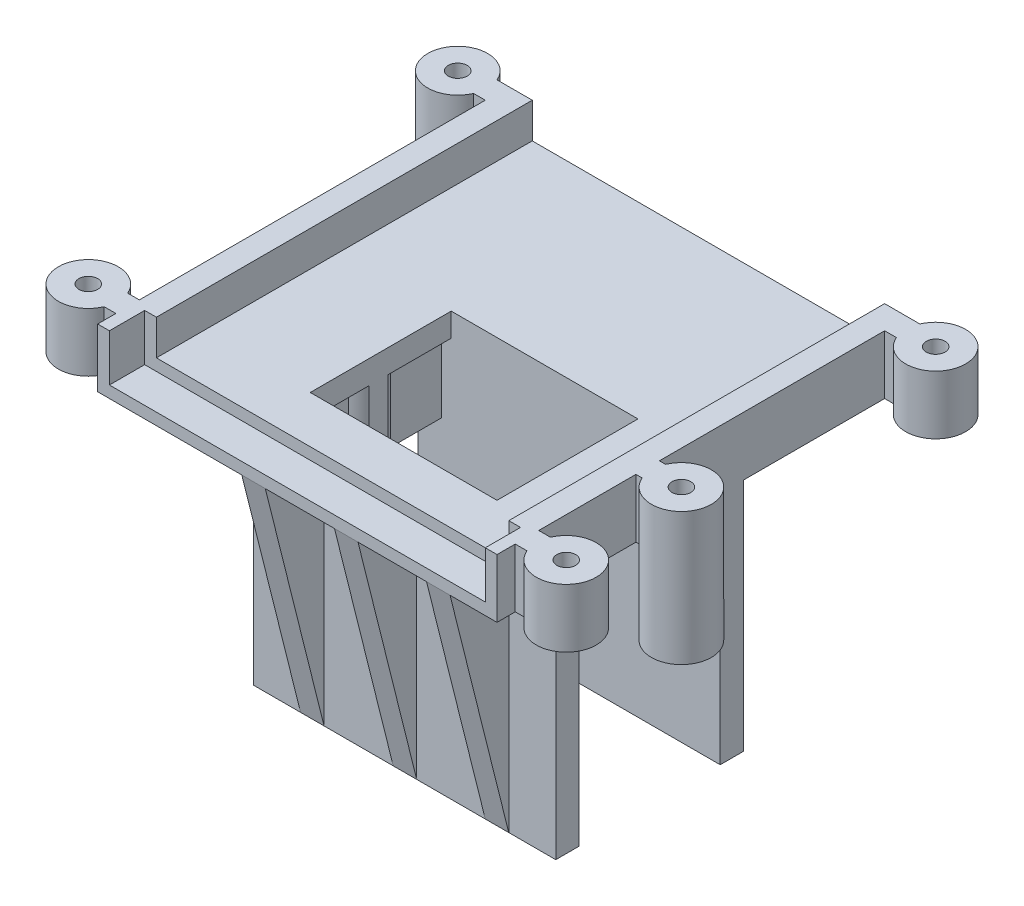
from build123d import *

# Parameters (mm, degrees)
BOSS_EXTRU_1_DEPTH       = 35
ENL_V_MAT_EXTRU_1_DEPTH  = 3
ENL_V_START              = -2
ESQUISSE3_W              = 14
ESQUISSE3_H              = 12
ENL_V_MAT_EXTRU_2_DEPTH  = 2
ESQUISSE7_W              = 3
ESQUISSE7_H              = 12
ENL_V_MAT_EXTRU_4_DEPTH  = 2
BOSS_EXTRU_4_START       = -2
ESQUISSE9_W              = 1.1
ESQUISSE9_H              = 12
BOSS_EXTRU_4_DEPTH       = 2
ESQUISSE10_R             = 0.8
BOSS_EXTRU_5_DEPTH       = 6.285817
ESQUISSE19_W             = 2
ESQUISSE19_H             = 4.092832792
ESQUISSE19_H_2           = 4.443065592
ESQUISSE19_W_2           = 4
ESQUISSE19_H_3           = 2
BOSS_EXTRU_8_DEPTH       = 6.285817
ENL_V_MAT_EXTRU_9_DEPTH  = 2
ESQUISSE25_R             = 0.8
BOSS_EXTRU_10_DEPTH      = 5
ESQUISSE26_R             = 0.8
BOSS_EXTRU_11_DEPTH      = 5
ESQUISSE27_R             = 0.8
BOSS_EXTRU_12_DEPTH      = 5
ESQUISSE28_R             = 2.55
ESQUISSE28_R_2           = 0.8
BOSS_EXTRU_13_DEPTH      = 6.290743
ENL_V_START_2            = -6.290743
ESQUISSE29_W             = 1.350487441
ESQUISSE29_H             = 4.654500935
ENL_V_MAT_EXTRU_11_DEPTH = 6.290743
BOSS_EXTRU_14_DEPTH      = 20
ENL_V_START_3            = -17.727203
ENL_V_MAT_EXTRU_12_DEPTH = 17.727203


with BuildPart() as part:
    # Esquisse1 → Boss.-Extru.1 (new body)
    with BuildSketch(Plane.XY):
        Polygon((0, 0), (34, 0), (34, 5), (32, 5), (32, 2), (2, 2), (2, 5), (0, 5), align=None)
    extrude(amount=BOSS_EXTRU_1_DEPTH)

    # Esquisse2 → Enl_v. mat.-Extru.1 (cut)
    with BuildSketch(Plane.XY.offset(35)):
        Polygon((2, 5), (1, 5), (1, 1), (33, 1), (33, 5), (32, 5), (32, 2), (2, 2), align=None)
    extrude(amount=-ENL_V_MAT_EXTRU_1_DEPTH, mode=Mode.SUBTRACT)

    # Esquisse3 → Enl_v. mat.-Extru.2 (cut)
    with BuildSketch(Plane(origin=(0, 2, 0), x_dir=(1, 0, 0), z_dir=(0, 1, 0)).offset(ENL_V_START)):
        with Locations((17, -22)):
            Rectangle(ESQUISSE3_W, ESQUISSE3_H)
    extrude(amount=ENL_V_MAT_EXTRU_2_DEPTH, mode=Mode.SUBTRACT)

    # Esquisse7 → Enl_v. mat.-Extru.4 (cut)
    with BuildSketch(Plane.XZ.offset(ENL_V_START)):
        with Locations((25.5, 22)):
            Rectangle(ESQUISSE7_W, ESQUISSE7_H)
    extrude(amount=ENL_V_MAT_EXTRU_4_DEPTH, mode=Mode.SUBTRACT)

    # Esquisse9 → Boss.-Extru.4 (add)
    with BuildSketch(Plane.XZ.offset(BOSS_EXTRU_4_START)):
        with Locations((10.55, 22)):
            Rectangle(ESQUISSE9_W, ESQUISSE9_H)
    extrude(amount=BOSS_EXTRU_4_DEPTH)

    # Esquisse10 → Boss.-Extru.5 (add)
    with BuildSketch(Plane.XZ):
        with BuildLine():
            Line((11.1, 22.988338073), (11.1, 21.361894727))
            ThreePointArc((11.1, 21.361894727), (7.27279708, 22.1751164), (11.1, 22.988338073))
        make_face()
        with Locations(Location((9.27279708, 22.1751164, 0), (0, 0, 90))):
            Circle(ESQUISSE10_R, mode=Mode.SUBTRACT)
    extrude(amount=BOSS_EXTRU_5_DEPTH)

    # Esquisse19 → Boss.-Extru.8 (add)
    with BuildSketch(Plane.XZ):
        with Locations((9.27279708, 25.953583604)):
            Rectangle(ESQUISSE19_W, ESQUISSE19_H)
        with Locations((9.27279708, 18.221532796)):
            Rectangle(ESQUISSE19_W, ESQUISSE19_H_2)
        with Locations((5.540746272, 22.1751164)):
            Rectangle(ESQUISSE19_W_2, ESQUISSE19_H_3)
    extrude(amount=BOSS_EXTRU_8_DEPTH)

    # Esquisse21 → Enl_v. mat.-Extru.9 (cut)
    with BuildSketch(Plane(origin=(0, 0, 21.1751164), x_dir=(-1, 0, 0), z_dir=(0, 0, -1))):
        Polygon((-3.540746272, 0), (-7.540746272, -6.285817331), (-3.540746272, -6.285817331), align=None)
    extrude(amount=-ENL_V_MAT_EXTRU_9_DEPTH, mode=Mode.SUBTRACT)

    # Esquisse25 → Boss.-Extru.10 (add)
    with BuildSketch(Plane.XZ):
        with BuildLine():
            Line((0, 31.45), (-1, 31.45))
            ThreePointArc((-1, 31.45), (-5.895740821, 32.45), (-1, 33.45))
            Line((-1, 33.45), (0, 33.45))
            Line((0, 33.45), (0, 31.45))
        make_face()
        with Locations(Location((-3.345740821, 32.45, 0), (0, 0, 270))):
            Circle(ESQUISSE25_R, mode=Mode.SUBTRACT)
        with BuildLine():
            Line((34, 33.45), (35, 33.45))
            ThreePointArc((35, 33.45), (39.895740821, 32.45), (35, 31.45))
            Line((35, 31.45), (34, 31.45))
            Line((34, 31.45), (34, 33.45))
        make_face()
        with Locations(Location((37.345740821, 32.45, 0), (0, 0, 90))):
            Circle(ESQUISSE25_R, mode=Mode.SUBTRACT)
    extrude(amount=-BOSS_EXTRU_10_DEPTH)

    # Esquisse26 → Boss.-Extru.11 (add)
    with BuildSketch(Plane.XZ):
        with BuildLine():
            Line((-1, 2), (0, 2))
            Line((0, 2), (0, 0))
            Line((0, 0), (-1, 0))
            ThreePointArc((-1, 0), (-5.895740821, 1), (-1, 2))
        make_face()
        with Locations(Location((-3.345740821, 1, 0), (0, 0, 270))):
            Circle(ESQUISSE26_R, mode=Mode.SUBTRACT)
        with BuildLine():
            Line((34, 2), (34, 0))
            Line((34, 0), (35, 0))
            ThreePointArc((35, 0), (39.895740821, 1), (35, 2))
            Line((35, 2), (34, 2))
        make_face()
        with Locations(Location((37.345740821, 1, 0), (0, 0, 90))):
            Circle(ESQUISSE26_R, mode=Mode.SUBTRACT)
    extrude(amount=-BOSS_EXTRU_11_DEPTH)

    # Esquisse27 → Boss.-Extru.12 (add)
    with BuildSketch(Plane(origin=(0, 0, 0), x_dir=(-1, 0, 0), z_dir=(0, -1, 0))):
        with BuildLine():
            Line((-34, -21.1751164), (-34.527056259, -21.1751164))
            ThreePointArc((-34.527056259, -21.1751164), (-39.42279708, -22.1751164), (-34.527056259, -23.1751164))
            Line((-34.527056259, -23.1751164), (-34, -23.1751164))
            Line((-34, -23.1751164), (-34, -21.1751164))
        make_face()
        with Locations(Location((-36.87279708, -22.1751164, 0), (0, 0, 90))):
            Circle(ESQUISSE27_R, mode=Mode.SUBTRACT)
    extrude(amount=-BOSS_EXTRU_12_DEPTH)

    # Esquisse28 → Boss.-Extru.13 (add)
    with BuildSketch(Plane.XZ):
        with Locations(Location((36.87279708, 22.1751164, 0), (0, 0, 270))):
            Circle(ESQUISSE28_R)
        with Locations(Location((36.87279708, 22.1751164, 0), (0, 0, 270))):
            Circle(ESQUISSE28_R_2, mode=Mode.SUBTRACT)
    extrude(amount=BOSS_EXTRU_13_DEPTH)

    # Esquisse29 → Enl_v. mat.-Extru.11 (cut)
    with BuildSketch(Plane.XZ.offset(6.290743087).offset(ENL_V_START_2)):
        with Locations((34.324427693, 22.303512705)):
            Rectangle(ESQUISSE29_W, ESQUISSE29_H)
    extrude(amount=ENL_V_MAT_EXTRU_11_DEPTH, mode=Mode.SUBTRACT)

    # Esquisse30 → Boss.-Extru.14 (add)
    with BuildSketch(Plane.XZ):
        Polygon((8.27279708, 28), (34, 28), (34, 30), (30, 30), (30, 35), (28, 35), (28, 30), (22.16279708, 30), (22.16279708, 35), (20.16279708, 35), (20.16279708, 30), (14.27279708, 30), (14.27279708, 35), (12.27279708, 35), (12.27279708, 30), (8.27279708, 30), align=None)
        Polygon((8.27279708, 16), (34, 16), (34, 14), (30, 14), (30, 9), (28, 9), (28, 14), (22.11, 14), (22.11, 9), (20.11, 9), (20.11, 14), (14.27279708, 14), (14.27279708, 9), (12.27279708, 9), (12.27279708, 14), (8.27279708, 14), align=None)
    extrude(amount=BOSS_EXTRU_14_DEPTH)

    # Esquisse31 → Enl_v. mat.-Extru.12 (cut)
    with BuildSketch(Plane(origin=(30, 0, 0), x_dir=(0, 0, -1), z_dir=(1, 0, 0)).offset(ENL_V_START_3)):
        Polygon((-35, 0), (-30, -20), (-35, -20), align=None)
        Polygon((-9, 0), (-14, -20), (-9, -20), align=None)
    extrude(amount=ENL_V_MAT_EXTRU_12_DEPTH, mode=Mode.SUBTRACT)


solid = part.part
